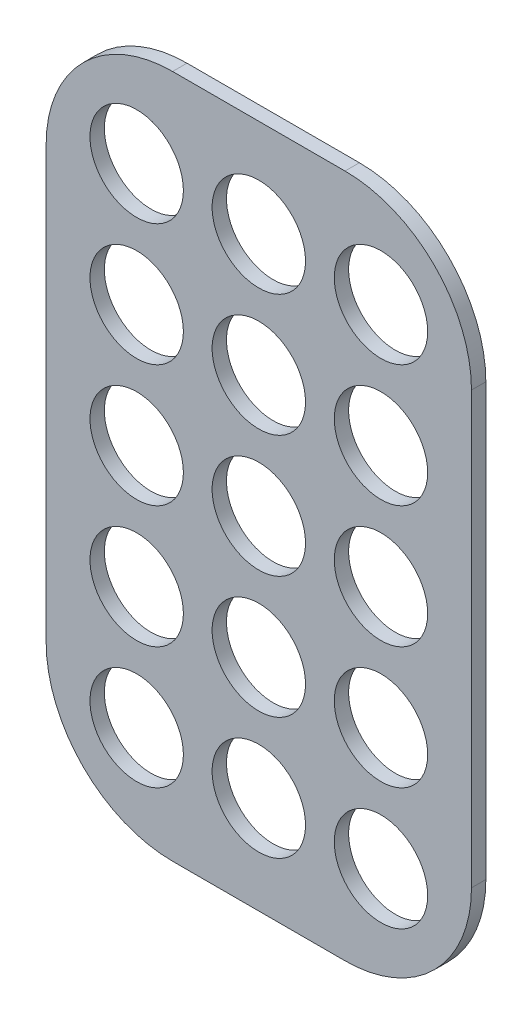
from build123d import *

# Parameters (mm, degrees)
SKETCH1_W               = 95.2
SKETCH1_H               = 59.2
BOSS_EXTRUDE1_DEPTH     = 2
SKETCH2_R               = 6.5
CUT_EXTRUDE2_DEPTH      = 1
CUT_EXTRUDE2_DEPTH_BACK = 3
FILLET1_R               = 17.6


with BuildPart() as part:
    # Sketch1 → Boss-Extrude1 (new body)
    with BuildSketch(Plane(origin=(0, 0, 0), x_dir=(0, 1, 0), z_dir=(0, 0, 1))):
        with Locations((0, 29.6)):
            Rectangle(SKETCH1_W, SKETCH1_H)
    extrude(amount=BOSS_EXTRUDE1_DEPTH)

    # Sketch2 → Cut-Extrude2 (cut, two sides)
    with BuildSketch(Plane.XY.offset(2)) as cut_extrude2_sk:
        with Locations((-29.6, 0)):
            Circle(SKETCH2_R)
        with Locations((-46.6, 0)):
            Circle(SKETCH2_R)
        with Locations((-12.6, 0)):
            Circle(SKETCH2_R)
        with Locations((-12.6, -17)):
            Circle(SKETCH2_R)
        with Locations((-46.6, -17)):
            Circle(SKETCH2_R)
        with Locations((-29.6, -17)):
            Circle(SKETCH2_R)
        with Locations((-12.6, -34)):
            Circle(SKETCH2_R)
        with Locations((-46.6, -34)):
            Circle(SKETCH2_R)
        with Locations((-29.6, -34)):
            Circle(SKETCH2_R)
        with Locations((-46.6, 17)):
            Circle(SKETCH2_R)
        with Locations((-29.6, 17)):
            Circle(SKETCH2_R)
        with Locations((-12.6, 17)):
            Circle(SKETCH2_R)
        with Locations((-46.6, 34)):
            Circle(SKETCH2_R)
        with Locations((-29.6, 34)):
            Circle(SKETCH2_R)
        with Locations((-12.6, 34)):
            Circle(SKETCH2_R)
    extrude(amount=CUT_EXTRUDE2_DEPTH, mode=Mode.SUBTRACT)
    extrude(cut_extrude2_sk.sketch, amount=-CUT_EXTRUDE2_DEPTH_BACK, mode=Mode.SUBTRACT)

    # Fillet1
    fillet1_edges = [part.edges().sort_by_distance(p)[0] for p in [
        (-59.2, -47.6, 1),
        (-59.2, 47.6, 1),
        (0, 47.6, 1),
        (0, -47.6, 1),
    ]]
    fillet(fillet1_edges, radius=FILLET1_R)


solid = part.part
